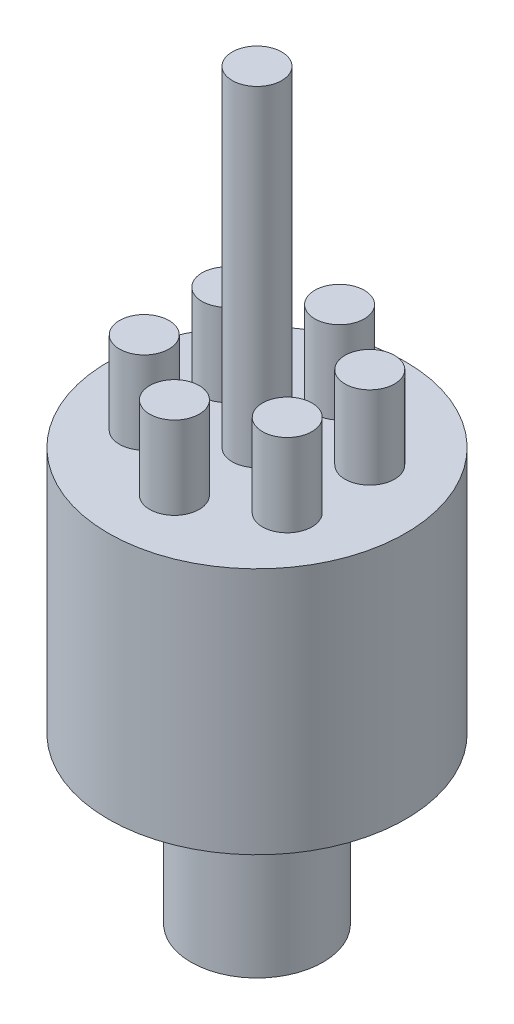
from build123d import *

# Parameters (mm, degrees)
SKETCH2_R           = 3
BOSS_EXTRUDE1_DEPTH = 10
CIRPATTERN1_COUNT   = 6


with BuildPart() as part:
    # Sketch1 → Revolve1 (revolve)
    with BuildSketch(Plane(origin=(0, 0, 0), x_dir=(0, 0, -1), z_dir=(1, 0, 0))):
        Polygon((0, 0), (-8, 0), (-8, 20), (-18, 20), (-18, 50), (-3, 50), (-3, 90), (0, 90), align=None)
    revolve(axis=Axis((0, 90, 0), (0, -1, 0)))

    # Sketch2 → Boss-Extrude1 (add)
    with BuildSketch(Plane(origin=(0, 50, 0), x_dir=(1, 0, 0), z_dir=(0, 1, 0))):
        with Locations((0, 10)):
            Circle(SKETCH2_R)
    boss_extrude1 = extrude(amount=BOSS_EXTRUDE1_DEPTH)

    # CirPattern1: Boss-Extrude1 ×6 about axis
    cirpattern1_axis = Axis((0, 0, 0), (0, 1, 0))
    for i in range(1, CIRPATTERN1_COUNT):
        add(boss_extrude1.rotate(cirpattern1_axis, i * 360 / CIRPATTERN1_COUNT))


solid = part.part
